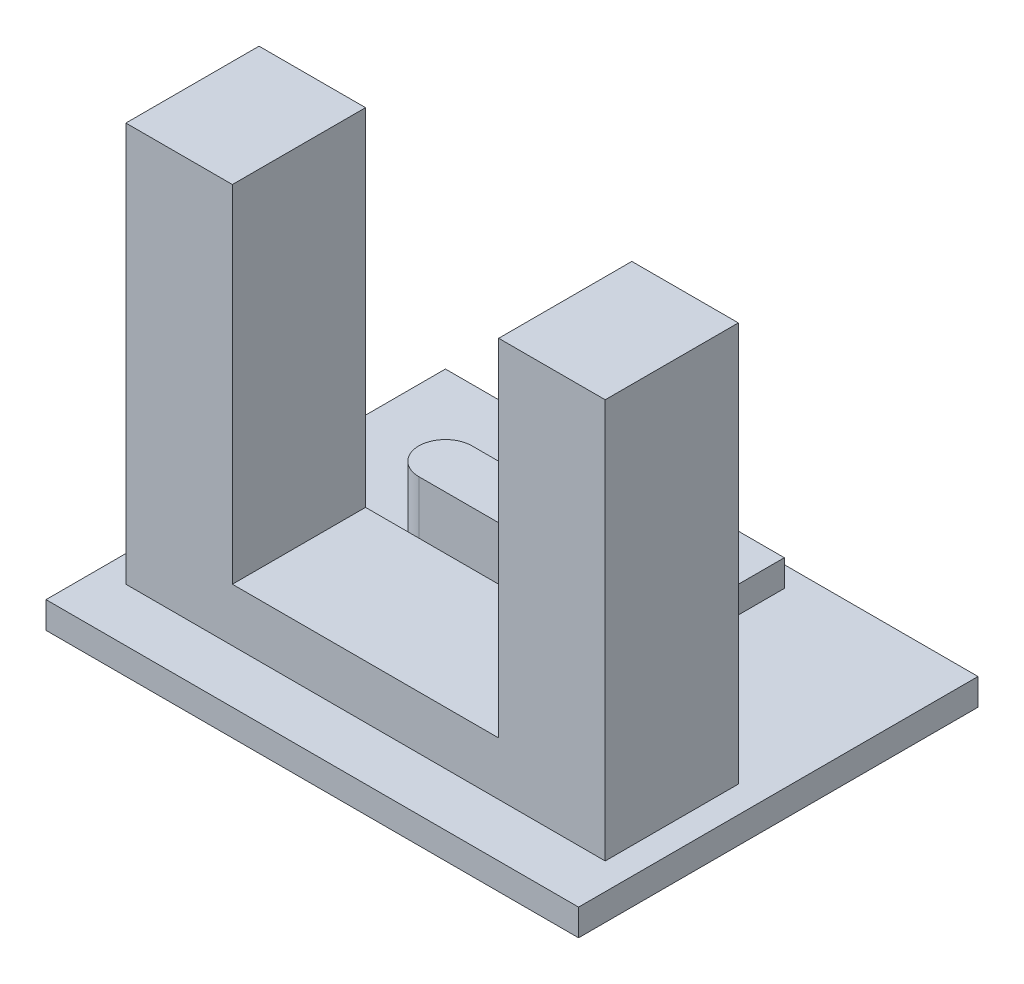
from build123d import *

# Parameters (mm, degrees)
ESQUISSE1_W             = 20
ESQUISSE1_H             = 15
BOSS_EXTRU_3_DEPTH      = 1
ESQUISSE1_5_W           = 10
ESQUISSE1_5_H           = 5
BOSS_EXTRU_4_DEPTH      = 2
ESQUISSE1_6_W           = 4
ESQUISSE1_6_H           = 5
BOSS_EXTRU_5_DEPTH      = 15
BOSS_EXTRU_6_DEPTH      = 3
BOSS_EXTRU_7_DEPTH      = 1
BOSS_EXTRU_7_DEPTH_BACK = 4
ESQUISSE1_8_W           = 7
ESQUISSE1_8_H           = 2
ESQUISSE1_8_R           = 0.15
BOSS_EXTRU_8_START      = -8
ESQUISSE1_9_R           = 0.15
BOSS_EXTRU_8_DEPTH      = 8


with BuildPart() as part:
    # Esquisse1 → Boss.-Extru.3 (new body)
    with BuildSketch(Plane(origin=(0, 0, 0), x_dir=(1, 0, 0), z_dir=(0, 1, 0))):
        with Locations((-29.903190877, 15.678459307)):
            Rectangle(ESQUISSE1_W, ESQUISSE1_H)
    extrude(amount=-BOSS_EXTRU_3_DEPTH)

    # Esquisse1_5 → Boss.-Extru.4 (add)
    with BuildSketch(Plane(origin=(0, 0, 0), x_dir=(1, 0, 0), z_dir=(0, 1, 0))):
        with Locations((-29.903190877, 12.678459307)):
            Rectangle(ESQUISSE1_5_W, ESQUISSE1_5_H)
    extrude(amount=BOSS_EXTRU_4_DEPTH)

    # Esquisse1_6 → Boss.-Extru.5 (add)
    with BuildSketch(Plane(origin=(0, 0, 0), x_dir=(1, 0, 0), z_dir=(0, 1, 0))):
        with Locations((-36.903190877, 12.678459307)):
            Rectangle(ESQUISSE1_6_W, ESQUISSE1_6_H)
        with Locations((-22.903190877, 12.678459307)):
            Rectangle(ESQUISSE1_6_W, ESQUISSE1_6_H)
    extrude(amount=BOSS_EXTRU_5_DEPTH)

    # Esquisse1_7 → Boss.-Extru.6 (add)
    with BuildSketch(Plane(origin=(0, 0, 0), x_dir=(1, 0, 0), z_dir=(0, 1, 0))):
        with BuildLine():
            Line((-25.903190877, 18.178459307), (-33.903190877, 18.178459307))
            ThreePointArc((-33.903190877, 18.178459307), (-34.903190877, 17.178459307), (-33.903190877, 16.178459307))
            Line((-33.903190877, 16.178459307), (-25.903190877, 16.178459307))
            ThreePointArc((-25.903190877, 16.178459307), (-24.903190877, 17.178459307), (-25.903190877, 18.178459307))
        make_face()
    extrude(amount=BOSS_EXTRU_6_DEPTH)

    # Esquisse1_8 → Boss.-Extru.7 (add, two sides: drawn at the far end of the back side and taken through both)
    with BuildSketch(Plane(origin=(0, 0, 0), x_dir=(1, 0, 0), z_dir=(0, 1, 0)).offset(-BOSS_EXTRU_7_DEPTH_BACK)):
        with Locations((-29.903190877, 21.405559188)):
            Rectangle(ESQUISSE1_8_W, ESQUISSE1_8_H)
        with Locations((-31.903190877, 21.405559188)):
            Circle(ESQUISSE1_8_R, mode=Mode.SUBTRACT)
        with Locations((-29.903190877, 21.405559188)):
            Circle(ESQUISSE1_8_R, mode=Mode.SUBTRACT)
        with Locations((-27.903190877, 21.405559188)):
            Circle(ESQUISSE1_8_R, mode=Mode.SUBTRACT)
    extrude(amount=BOSS_EXTRU_7_DEPTH + BOSS_EXTRU_7_DEPTH_BACK)

    # Esquisse1_9 → Boss.-Extru.8 (add)
    with BuildSketch(Plane(origin=(0, 0, 0), x_dir=(1, 0, 0), z_dir=(0, 1, 0)).offset(BOSS_EXTRU_8_START)):
        with Locations((-31.903190877, 21.405559188)):
            Circle(ESQUISSE1_9_R)
        with Locations((-29.903190877, 21.405559188)):
            Circle(ESQUISSE1_9_R)
        with Locations((-27.903190877, 21.405559188)):
            Circle(ESQUISSE1_9_R)
    extrude(amount=BOSS_EXTRU_8_DEPTH)


solid = part.part
